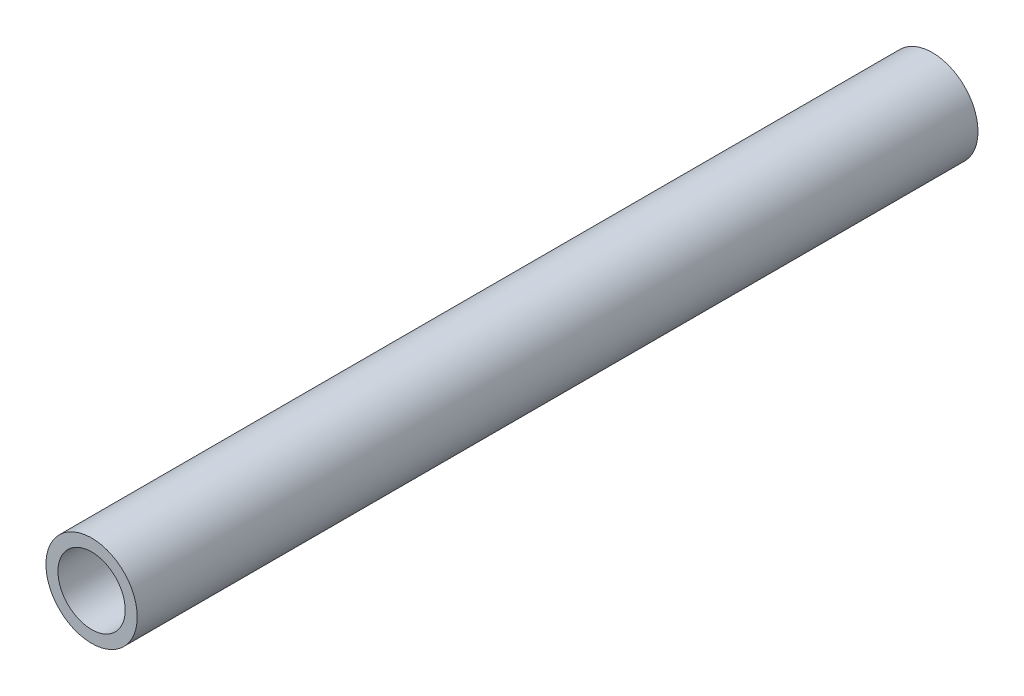
from build123d import *

# Parameters (mm, degrees)
SKETCH1_R           = 4.826
SKETCH1_R_2         = 3.556
BOSS_EXTRUDE1_DEPTH = 88.8746


with BuildPart() as part:
    # Sketch1 → Boss-Extrude1 (new body)
    with BuildSketch(Plane.XY):
        Circle(SKETCH1_R)
        Circle(SKETCH1_R_2, mode=Mode.SUBTRACT)
    extrude(amount=BOSS_EXTRUDE1_DEPTH)


solid = part.part
